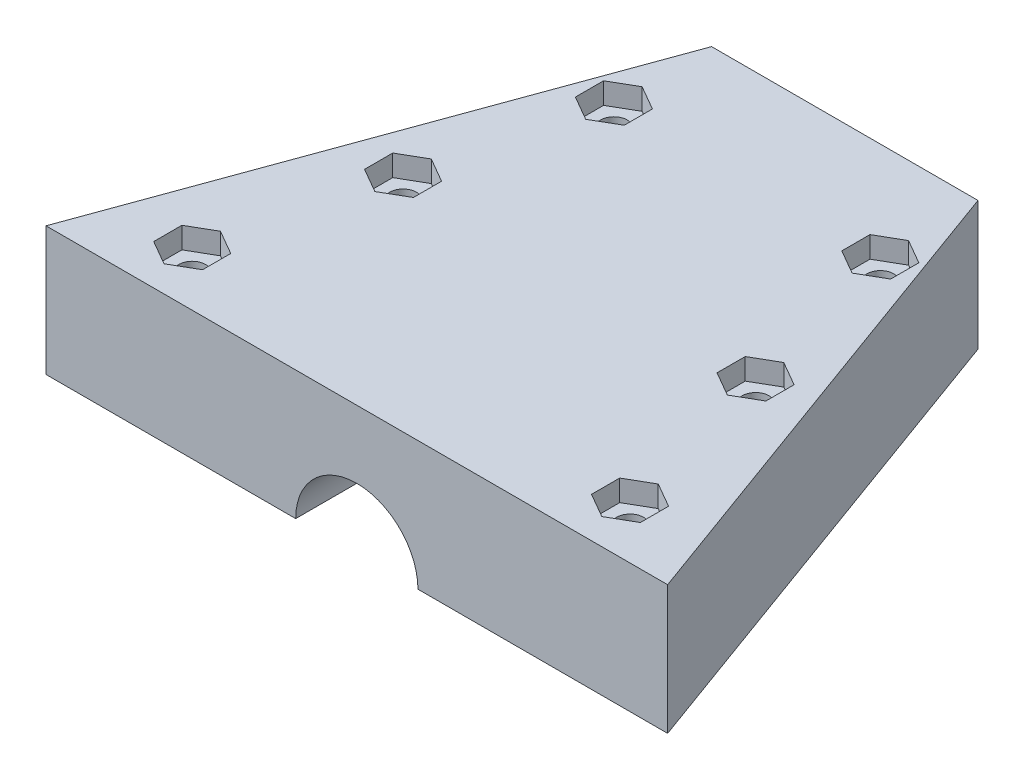
from build123d import *

# Parameters (mm, degrees)
BOSS_EXTRUDE3_DEPTH              = 14.5
SKETCH8_R                        = 6.884606738
CUT_EXTRUDE3_DEPTH               = 88
CUT_EXTRUDE4_DEPTH               = 2.4
CUT_EXTRUDE5_DEPTH               = 2.4
F_39_0_11811024_DIAMETER_HOLE1_D = 3.000000096


with BuildPart() as part:
    # Sketch6 → Boss-Extrude3 (new body)
    with BuildSketch(Plane(origin=(0, 0, 0), x_dir=(1, 0, 0), z_dir=(0, 1, 0))):
        Polygon((-16.836914056, 5.783353512), (13.163085944, 5.783353512), (33.163085944, -49.166194877), (-36.836914056, -49.166194877), align=None)
    extrude(amount=BOSS_EXTRUDE3_DEPTH)

    # Sketch8 → Cut-Extrude3 (cut)
    with BuildSketch(Plane.XY.offset(49.166194877)):
        with Locations((-1.836914056, 0)):
            Circle(SKETCH8_R)
    extrude(amount=-CUT_EXTRUDE3_DEPTH, mode=Mode.SUBTRACT)

    # Sketch9 → Cut-Extrude4 (cut)
    with BuildSketch(Plane(origin=(0, 14.5, 0), x_dir=(1, 0, 0), z_dir=(0, 1, 0))):
        Polygon((-21.661914056, -27.308299801), (-18.911914056, -25.72058656), (-18.911914056, -22.54516008), (-21.661914056, -20.95744684), (-24.411914056, -22.54516008), (-24.411914056, -25.72058656), align=None)
        Polygon((-26.486914056, -46.224526633), (-23.736914056, -44.636813392), (-23.736914056, -41.461386912), (-26.486914056, -39.873673672), (-29.236914056, -41.461386912), (-29.236914056, -44.636813392), align=None)
        Polygon((22.813085944, -46.224526633), (25.563085944, -44.636813392), (25.563085944, -41.461386912), (22.813085944, -39.873673672), (20.063085944, -41.461386912), (20.063085944, -44.636813392), align=None)
        Polygon((18.031463076, -27.308299801), (20.781463076, -25.72058656), (20.781463076, -22.54516008), (18.031463076, -20.95744684), (15.281463076, -22.54516008), (15.281463076, -25.72058656), align=None)
        Polygon((-16.836914056, -8.392072969), (-14.086914056, -6.804359728), (-14.086914056, -3.628933248), (-16.836914056, -2.041220008), (-19.586914056, -3.628933248), (-19.586914056, -6.804359728), align=None)
        Polygon((13.163085944, -8.392072969), (15.913085944, -6.804359728), (15.913085944, -3.628933248), (13.163085944, -2.041220008), (10.413085944, -3.628933248), (10.413085944, -6.804359728), align=None)
    extrude(amount=-CUT_EXTRUDE4_DEPTH, mode=Mode.SUBTRACT)

    # Sketch10 → Cut-Extrude5 (cut)
    with BuildSketch(Plane.XZ):
        Polygon((-26.486914056, 39.873673672), (-23.736914056, 41.461386912), (-23.736914056, 44.636813392), (-26.486914056, 46.224526633), (-29.236914056, 44.636813392), (-29.236914056, 41.461386912), align=None)
        Polygon((-21.661914056, 20.95744684), (-18.911914056, 22.54516008), (-18.911914056, 25.72058656), (-21.661914056, 27.308299801), (-24.411914056, 25.72058656), (-24.411914056, 22.54516008), align=None)
        Polygon((18.031463076, 20.95744684), (20.781463076, 22.54516008), (20.781463076, 25.72058656), (18.031463076, 27.308299801), (15.281463076, 25.72058656), (15.281463076, 22.54516008), align=None)
        Polygon((22.813085944, 39.873673672), (25.563085944, 41.461386912), (25.563085944, 44.636813392), (22.813085944, 46.224526633), (20.063085944, 44.636813392), (20.063085944, 41.461386912), align=None)
        Polygon((-16.836914056, 2.041220008), (-14.086914056, 3.628933248), (-14.086914056, 6.804359728), (-16.836914056, 8.392072969), (-19.586914056, 6.804359728), (-19.586914056, 3.628933248), align=None)
        Polygon((13.163085944, 2.041220008), (15.913085944, 3.628933248), (15.913085944, 6.804359728), (13.163085944, 8.392072969), (10.413085944, 6.804359728), (10.413085944, 3.628933248), align=None)
    extrude(amount=-CUT_EXTRUDE5_DEPTH, mode=Mode.SUBTRACT)

    # #39 (0.11811024) Diameter Hole1 (through all)
    with Locations(Plane(origin=(-16.836914056, 14.5, 5.216646488), x_dir=(0, 0, 1), z_dir=(0, 1, 0))):
        with Locations((0, 0), (0, 30), (18.916226832, 34.868377132), (18.916226832, -4.825), (37.832453664, -9.65), (37.832453664, 39.65)):
            Hole(F_39_0_11811024_DIAMETER_HOLE1_D / 2)


solid = part.part
